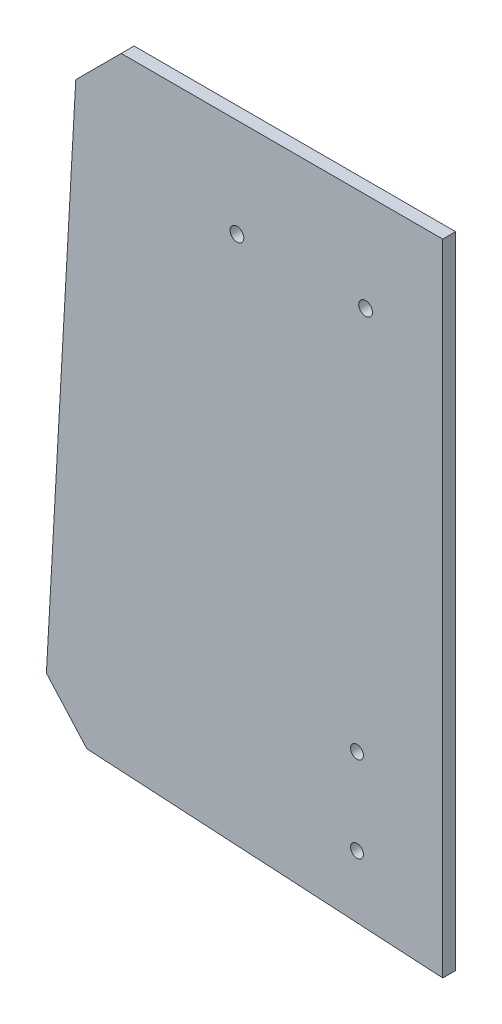
from build123d import *
from OCP.BRepFilletAPI import BRepFilletAPI_MakeChamfer

# Parameters (mm, degrees)
SKETCH1_R           = 1.6
SKETCH1_R_2         = 1.5
BOSS_EXTRUDE1_DEPTH = 3
CHAMFER1_SIZE       = 10
CHAMFER1_SIZE2      = 10.020818191
CHAMFER1_SIZE2_2    = 10.605077774


with BuildPart() as part:
    # Sketch1 → Boss-Extrude1 (new body)
    with BuildSketch(Plane.XY):
        Polygon((-82, 33.355339059), (3, 33.355339059), (3, -115.896085726), (-90, -110.53173818), align=None)
        with Locations((-45, 10.355339059)):
            Circle(SKETCH1_R, mode=Mode.SUBTRACT)
        with Locations((-15, 10.355339059)):
            Circle(SKETCH1_R, mode=Mode.SUBTRACT)
        with Locations((-17, -80.208152802)):
            Circle(SKETCH1_R_2, mode=Mode.SUBTRACT)
        with Locations((-17, -100.208152802)):
            Circle(SKETCH1_R_2, mode=Mode.SUBTRACT)
    extrude(amount=BOSS_EXTRUDE1_DEPTH)

    # Chamfer1: one chamfer whose edges measure the first distance from different faces: ONE call of the kernel's chamfer builder (chamfer() names one face for all edges)
    chamfer1_edges_1 = [part.edges().sort_by_distance(p)[0] for p in [
        (-90, -110.53173818, 1.5),
    ]]
    chamfer1_side_1 = [part.faces().sort_by_distance(p)[0] for p in [
        (-86, -38.588199561, 1.5),
    ]]
    chamfer1_edges_2 = [part.edges().sort_by_distance(p)[0] for p in [
        (-82, 33.355339059, 1.5),
    ]]
    chamfer1_side_2 = [part.faces().sort_by_distance(p)[0] for p in [
        (-39.5, 33.355339059, 1.5),
    ]]
    chamfer1 = BRepFilletAPI_MakeChamfer(part.part.solid().wrapped)
    for e in chamfer1_edges_1:
        chamfer1.Add(CHAMFER1_SIZE, CHAMFER1_SIZE2, e.wrapped, chamfer1_side_1[0].wrapped)  # the first distance lies on this face
    for e in chamfer1_edges_2:
        chamfer1.Add(CHAMFER1_SIZE, CHAMFER1_SIZE2_2, e.wrapped, chamfer1_side_2[0].wrapped)  # the first distance lies on this face
    add(Compound.cast(chamfer1.Shape()), mode=Mode.REPLACE)


solid = part.part
